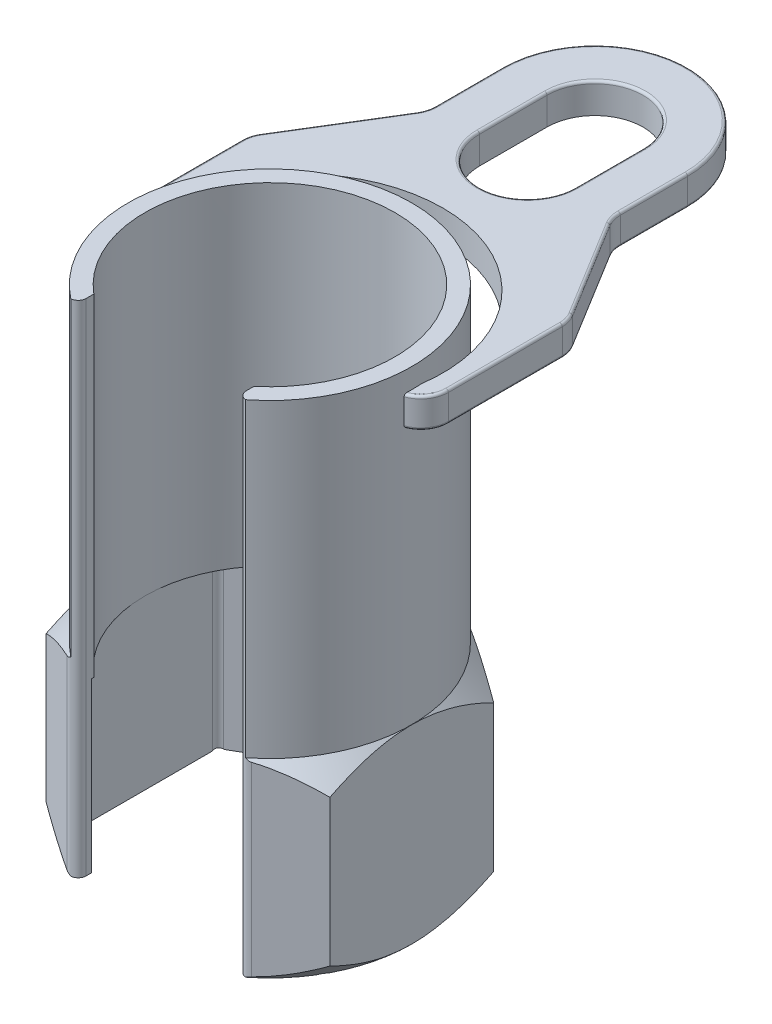
from build123d import *
from build123d.topology import SkipClean

# Parameters (mm, degrees)
EXTRUDE1_DEPTH     = 38
EXTRUDE2_DEPTH     = 62
SKETCH8_OUTSIDE_W  = 286.324
SKETCH8_OUTSIDE_H  = 285.862
SKETCH8_OUTSIDE_R  = 28.362331974
CUT_EXTRUDE4_DEPTH = 101
CUT_EXTRUDE4_DRAFT = -45
SKETCH19_OUTSIDE_W = 162.324
SKETCH19_OUTSIDE_H = 161.862
SKETCH19_OUTSIDE_R = 28.362231974
CUT_EXTRUDE6_DEPTH = 39
CUT_EXTRUDE6_DRAFT = -45
CUT_EXTRUDE9_START = -33.612232
CUT_EXTRUDE9_DEPTH = 33.612237
FILLET1_R          = 1.6
EXTRUDE7_DEPTH     = 6
CUT_EXTRUDE8_REACH = 98
FILLET4_R          = 0.5


with BuildPart() as part:
    # Sketch1 → Extrude1 (new body)
    with BuildSketch(Plane(origin=(0, 0, 0), x_dir=(1, 0, 0), z_dir=(0, 1, 0))):
        with BuildLine():
            Line((-16, -19.209372712), (-16, -23.512395693))
            Line((-16, -23.512395693), (-28.362331974, -16.375))
            Line((-28.362331974, -16.375), (-28.362331974, 16.375))
            Line((-28.362331974, 16.375), (0, 32.75))
            Line((0, 32.75), (28.362331974, 16.375))
            Line((28.362331974, 16.375), (28.362331974, -16.375))
            Line((28.362331974, -16.375), (16, -23.512395693))
            Line((16, -23.512395693), (16, -19.209372712))
            ThreePointArc((16, -19.209372712), (0, 25), (-16, -19.209372712))
        make_face()
    extrude(amount=EXTRUDE1_DEPTH)

    # Sketch3 → Extrude2 (add)
    with BuildSketch(Plane(origin=(0, 38, 0), x_dir=(-1, 0, 0), z_dir=(0, 1, 0))):
        with BuildLine():
            Line((-16, 23.41828778), (-16, 19.209372712))
            ThreePointArc((-16, 19.209372712), (0, -25), (16, 19.209372712))
            Line((16, 19.209372712), (16, 23.41828778))
            ThreePointArc((16, 23.41828778), (0, -28.362231974), (-16, 23.41828778))
        make_face()
    extrude(amount=EXTRUDE2_DEPTH)


with BuildPart() as cut_extrude4_tool:
    # Sketch8 outside → Cut-Extrude4 (with draft: the straight prism first)
    with BuildSketch(Plane.XZ):
        with Locations((0, -4.619)):
            Rectangle(SKETCH8_OUTSIDE_W, SKETCH8_OUTSIDE_H)
        Circle(SKETCH8_OUTSIDE_R, mode=Mode.SUBTRACT)
    extrude(amount=-CUT_EXTRUDE4_DEPTH)
    # Cut-Extrude4: the draft: its side faces are tilted about the plane it starts from
    cut_extrude4_sides = [cut_extrude4_tool.faces().sort_by_distance(p)[0] for p in [
        (0, 50.5, -147.55),
        (143.162, 50.5, -4.619),
        (0, 50.5, 138.312),
        (-143.162, 50.5, -4.619),
        (-28.362331974, 50.5, 0),
    ]]
    draft(cut_extrude4_sides, Plane.XZ, CUT_EXTRUDE4_DRAFT)


with BuildPart() as part_1:
    add(part.part)

    # Cut-Extrude4: cut by cut_extrude4_tool
    add(cut_extrude4_tool.part, mode=Mode.SUBTRACT)


with BuildPart() as cut_extrude6_tool:
    # Sketch19 outside → Cut-Extrude6 (with draft: the straight prism first)
    with BuildSketch(Plane(origin=(0, 38, 0), x_dir=(-1, 0, 0), z_dir=(0, 1, 0))):
        with Locations((0, -4.619)):
            Rectangle(SKETCH19_OUTSIDE_W, SKETCH19_OUTSIDE_H)
        Circle(SKETCH19_OUTSIDE_R, mode=Mode.SUBTRACT)
    extrude(amount=-CUT_EXTRUDE6_DEPTH)
    # Cut-Extrude6: the draft: its side faces are tilted about the plane it starts from
    cut_extrude6_sides = [cut_extrude6_tool.faces().sort_by_distance(p)[0] for p in [
        (0, 18.5, -85.55),
        (-81.162, 18.5, -4.619),
        (0, 18.5, 76.312),
        (81.162, 18.5, -4.619),
        (28.362231974, 18.5, 0),
    ]]
    draft(cut_extrude6_sides, Plane(origin=(0, 38, 0), x_dir=(-1, 0, 0), z_dir=(0, 1, 0)), CUT_EXTRUDE6_DRAFT)


with BuildPart() as part_2:
    add(part_1.part)

    # Cut-Extrude6: cut by cut_extrude6_tool
    add(cut_extrude6_tool.part, mode=Mode.SUBTRACT)

    # Sketch26 → Cut-Extrude9 (cut)
    with BuildSketch(Plane.XZ.offset(CUT_EXTRUDE9_START)):
        Polygon((-25, -14.43375673), (0, -28.867513459), (25, -14.43375673), (25, 14.43375673), (0, 28.867513459), (-25, 14.43375673), align=None)
    extrude(amount=CUT_EXTRUDE9_DEPTH, mode=Mode.SUBTRACT)

    # Fillet1
    fillet1_edges = [part_2.edges().sort_by_distance(p)[0] for p in [
        (-25, 17.058706743, -14.43375673),
        (-25, 17.058706743, 14.43375673),
        (25, 17.058706743, 14.43375673),
        (25, 17.058706743, -14.43375673),
        (-16, 18.99995, 23.512395693),
        (16, 18.99995, 23.512395693),
        (0, 17.058706743, -28.867513459),
    ]]
    fillet(fillet1_edges, radius=FILLET1_R)

    # Sketch16 → Extrude7 (add)
    with BuildSketch(Plane(origin=(0, 90, 0), x_dir=(-1, 0, 0), z_dir=(0, 1, 0))):
        with BuildLine():
            Line((-18.5, -65), (-18.5, -51.552963296))
            ThreePointArc((-18.5, -51.552963296), (-18.70694972, -50.058433694), (-19.312224992, -48.676374086))
            Line((-19.312224992, -48.676374086), (-31.187775008, -29.323625914))
            ThreePointArc((-31.187775008, -29.323625914), (-31.79305028, -27.941566306), (-32, -26.447036704))
            Line((-32, -26.447036704), (-32, -3.689253551))
            ThreePointArc((-32, -3.689253551), (-30.987424832, -0.509156324), (-28.322538773, 1.5))
            ThreePointArc((-28.322538773, 1.5), (0, -28.362231974), (28.322538773, 1.5))
            ThreePointArc((28.322538773, 1.5), (30.987424832, -0.509156324), (32, -3.689253551))
            Line((32, -3.689253551), (32, -26.447036704))
            ThreePointArc((32, -26.447036704), (31.79305028, -27.941566306), (31.187775008, -29.323625914))
            Line((31.187775008, -29.323625914), (19.312224992, -48.676374086))
            ThreePointArc((19.312224992, -48.676374086), (18.70694972, -50.058433694), (18.5, -51.552963296))
            Line((18.5, -51.552963296), (18.5, -65))
            ThreePointArc((18.5, -65), (0, -83.5), (-18.5, -65))
        make_face()
    extrude(amount=EXTRUDE7_DEPTH)

    # Sketch25 → Cut-Extrude8 (cut, up to next)
    with BuildSketch(Plane.XZ.offset(-96), mode=Mode.PRIVATE) as cut_extrude8_sk1:
        with BuildLine():
            Line((-9.6, -65), (-9.6, -51.5))
            ThreePointArc((-9.6, -51.5), (0, -41.9), (9.6, -51.5))
            Line((9.6, -51.5), (9.6, -65))
            ThreePointArc((9.6, -65), (0, -74.6), (-9.6, -65))
        make_face()
    cut_extrude8_tool1 = extrude(cut_extrude8_sk1.sketch, amount=CUT_EXTRUDE8_REACH, mode=Mode.PRIVATE) & part_2.part
    add(cut_extrude8_tool1.solids().sort_by_distance((0, 96, -58.25))[0], mode=Mode.SUBTRACT)
    # Sketch25 → Cut-Extrude8 (cut, up to next)
    with BuildSketch(Plane.XZ.offset(-96), mode=Mode.PRIVATE) as cut_extrude8_sk2:
        with BuildLine():
            ThreePointArc((28.291627782, -2), (0, -28.362231974), (-28.291627782, -2))
            ThreePointArc((-28.291627782, -2), (0, -34.572997787), (28.291627782, -2))
        make_face()
    cut_extrude8_tool2 = extrude(cut_extrude8_sk2.sketch, amount=CUT_EXTRUDE8_REACH, mode=Mode.PRIVATE) & part_2.part
    add(cut_extrude8_tool2.solids().sort_by_distance((0, 96, -29.020006))[0], mode=Mode.SUBTRACT)

    # Fillet4
    fillet4_edges = [part_2.edges().sort_by_distance(p)[0] for p in [
        (-30.987424832, 90, -0.509156324),
        (30.987424832, 90, -0.509156324),
        (32, 90, -15.068145128),
        (31.79305028, 90, -27.941566306),
        (25.25, 90, -39),
        (18.70694972, 90, -50.058433694),
        (18.5, 90, -58.276481648),
        (0, 90, -83.5),
        (-18.5, 90, -58.276481648),
        (-18.70694972, 90, -50.058433694),
        (-25.25, 90, -39),
        (-31.79305028, 90, -27.941566306),
        (-32, 90, -15.068145128),
        (-30.987424832, 96, -0.509156324),
        (30.987424832, 96, -0.509156324),
        (32, 96, -15.068145128),
        (31.79305028, 96, -27.941566306),
        (25.25, 96, -39),
        (18.70694972, 96, -50.058433694),
        (18.5, 96, -58.276481648),
        (0, 96, -83.5),
        (-18.5, 96, -58.276481648),
        (-18.70694972, 96, -50.058433694),
        (-25.25, 96, -39),
        (-31.79305028, 96, -27.941566306),
        (-32, 96, -15.068145128),
        (0, 96, -74.6),
        (9.6, 96, -58.25),
        (0, 96, -41.9),
        (-9.6, 96, -58.25),
    ]]
    fillet(fillet4_edges, radius=FILLET4_R)


solid = part_2.part
